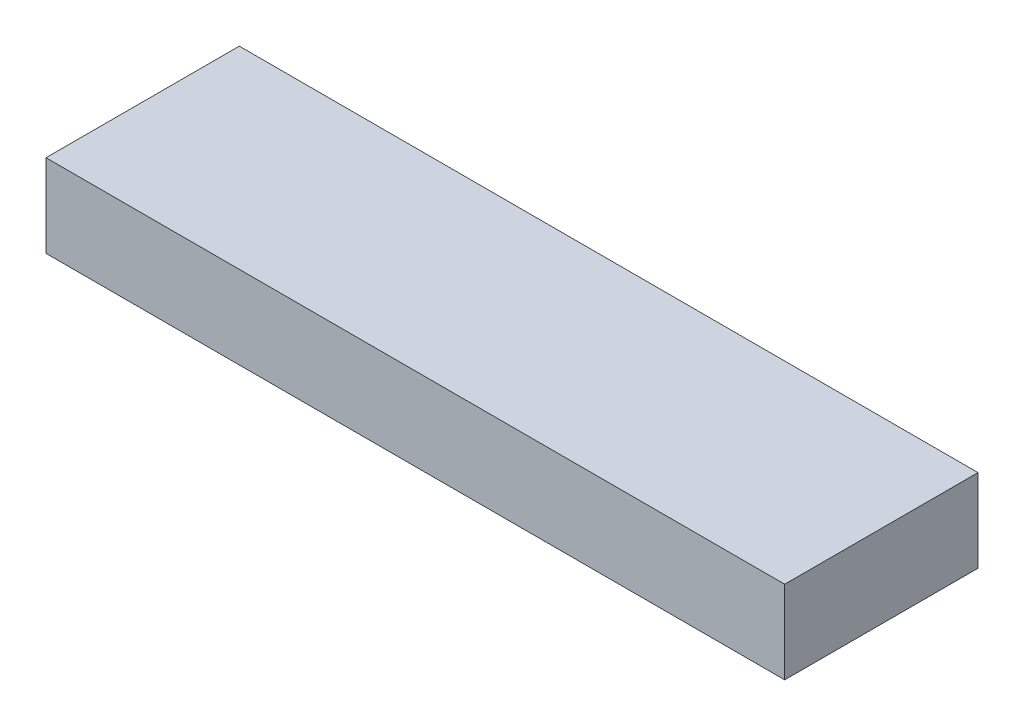
from build123d import *

# Parameters (mm, degrees)
SKETCH1_W           = 339.725
SKETCH1_H           = 88.9
BOSS_EXTRUDE1_DEPTH = 38.1


with BuildPart() as part:
    # Sketch1 → Boss-Extrude1 (new body)
    with BuildSketch(Plane(origin=(0, 0, 0), x_dir=(1, 0, 0), z_dir=(0, 1, 0))):
        with Locations((169.8625, 44.45)):
            Rectangle(SKETCH1_W, SKETCH1_H)
    extrude(amount=BOSS_EXTRUDE1_DEPTH)


solid = part.part
